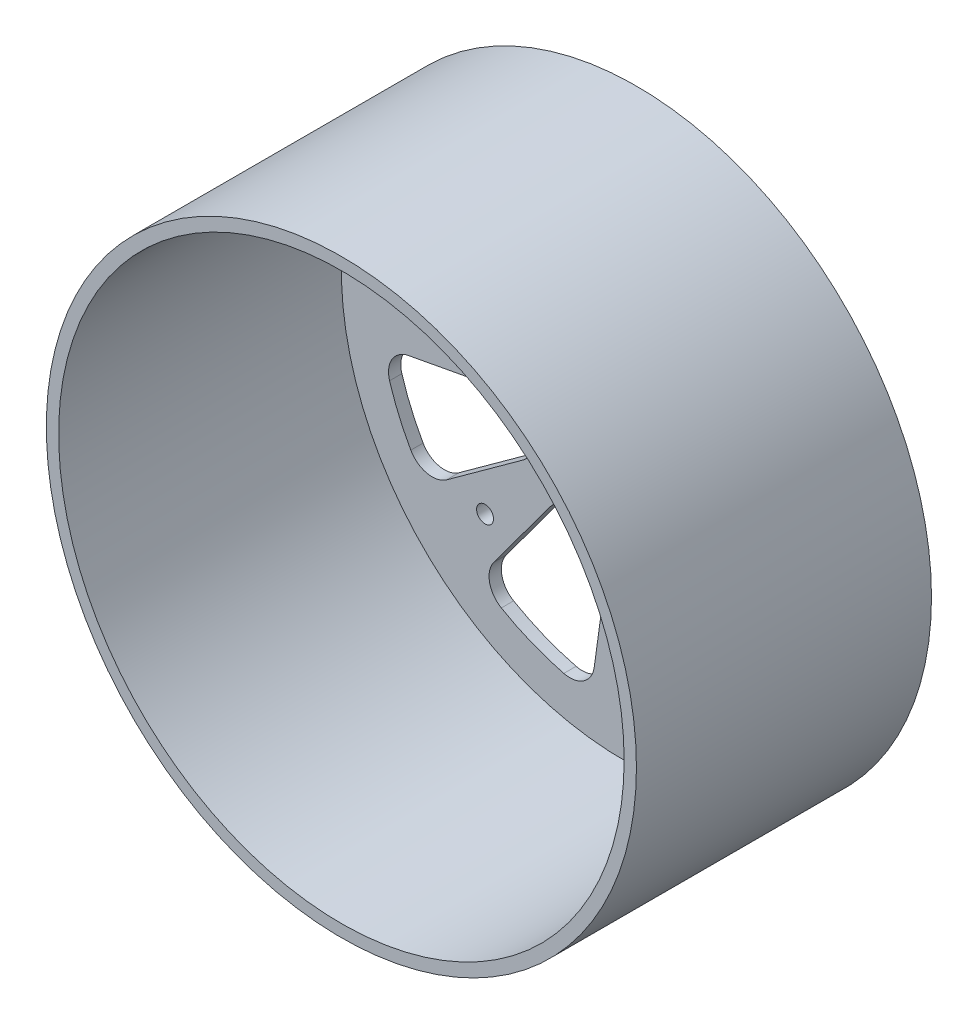
from build123d import *

# Parameters (mm, degrees)
SKETCH1_R           = 76.2
SKETCH1_R_2         = 73.025
BOSS_EXTRUDE1_DEPTH = 76.2
SKETCH3_R           = 76.2
BOSS_EXTRUDE2_DEPTH = 3.175
SKETCH5_R           = 2.1828125
CUT_EXTRUDE2_DEPTH  = 4.175
SKETCH11_R          = 2.1828125
CUT_EXTRUDE11_DEPTH = 4.175
SKETCH12_R          = 18.984546406
CUT_EXTRUDE12_DEPTH = 4.175
CUT_EXTRUDE13_DEPTH = 4.175
CIRPATTERN1_COUNT   = 4


with BuildPart() as part:
    # Sketch1 → Boss-Extrude1 (new body)
    with BuildSketch(Plane.XY):
        Circle(SKETCH1_R)
        Circle(SKETCH1_R_2, mode=Mode.SUBTRACT)
    extrude(amount=BOSS_EXTRUDE1_DEPTH)

    # Sketch3 → Boss-Extrude2 (add)
    with BuildSketch(Plane.XY):
        Circle(SKETCH3_R)
    extrude(amount=BOSS_EXTRUDE2_DEPTH)

    # Sketch5 → Cut-Extrude2 (cut, through all)
    with BuildSketch(Plane.XY.offset(3.175)):
        with Locations((0, 37.81298)):
            Circle(SKETCH5_R)
        with Locations((37.81298, 0)):
            Circle(SKETCH5_R)
        with Locations((-37.81298, 0)):
            Circle(SKETCH5_R)
        with Locations((0, -37.81298)):
            Circle(SKETCH5_R)
    extrude(amount=-CUT_EXTRUDE2_DEPTH, mode=Mode.SUBTRACT)

    # Sketch11 → Cut-Extrude11 (cut, through all)
    with BuildSketch(Plane.XY.offset(3.175)):
        with Locations((-35.921024484, 35.921024484)):
            Circle(SKETCH11_R)
        with Locations((-35.921024484, -35.921024484)):
            Circle(SKETCH11_R)
        with Locations((35.921024484, -35.921024484)):
            Circle(SKETCH11_R)
        with Locations((35.921024484, 35.921024484)):
            Circle(SKETCH11_R)
    extrude(amount=-CUT_EXTRUDE11_DEPTH, mode=Mode.SUBTRACT)

    # Sketch12 → Cut-Extrude12 (cut, through all)
    with BuildSketch(Plane.XY.offset(3.175)):
        Circle(SKETCH12_R)
    extrude(amount=-CUT_EXTRUDE12_DEPTH, mode=Mode.SUBTRACT)

    # Sketch13 → Cut-Extrude13 (cut, through all)
    with BuildSketch(Plane.XY.offset(3.175)):
        with BuildLine():
            Line((-18.887713582, 26.073256792), (-33.213845797, 45.849548003))
            ThreePointArc((-33.213845797, 45.849548003), (-34.276091741, 50.925360779), (-31.200233714, 55.10044631))
            ThreePointArc((-31.200233714, 55.10044631), (-24.962317442, 58.192752772), (-18.42261337, 60.581524279))
            ThreePointArc((-18.42261337, 60.581524279), (-13.277568117, 59.932870951), (-10.331766338, 55.665026803))
            Line((-10.331766338, 55.665026803), (-5.875364286, 31.655023908))
            ThreePointArc((-5.875364286, 31.655023908), (-6.559884807, 27.42673862), (-9.773713061, 24.595083138))
            ThreePointArc((-9.773713061, 24.595083138), (-10.43339446, 24.322579255), (-11.085487572, 24.032385376))
            ThreePointArc((-11.085487572, 24.032385376), (-15.352183804, 23.65520096), (-18.887713582, 26.073256792))
        make_face()
        with BuildLine():
            Line((-45.533204085, 33.646217178), (-25.893361536, 19.133590161))
            ThreePointArc((-25.893361536, 19.133590161), (-23.508869462, 15.575337449), (-23.926411262, 11.312401411))
            ThreePointArc((-23.926411262, 11.312401411), (-24.511909026, 9.980475814), (-25.023328549, 8.618387895))
            ThreePointArc((-25.023328549, 8.618387895), (-27.702333545, 5.276248304), (-31.894176796, 4.395671802))
            Line((-31.894176796, 4.395671802), (-56.085574643, 7.729742659))
            ThreePointArc((-56.085574643, 7.729742659), (-60.4859006, 10.473713006), (-61.373317696, 15.582992084))
            ThreePointArc((-61.373317696, 15.582992084), (-58.645731892, 23.878691299), (-54.802742327, 31.720233302))
            ThreePointArc((-54.802742327, 31.720233302), (-50.598737942, 34.756446226), (-45.533204085, 33.646217178))
        make_face()
    cut_extrude13 = extrude(amount=-CUT_EXTRUDE13_DEPTH, mode=Mode.SUBTRACT)

    # CirPattern1: Cut-Extrude13 ×4 about axis
    cirpattern1_axis = Axis((0, 0, 0), (0, 0, 1))
    for i in range(1, CIRPATTERN1_COUNT):
        add(cut_extrude13.rotate(cirpattern1_axis, i * 360 / CIRPATTERN1_COUNT), mode=Mode.SUBTRACT)


solid = part.part
